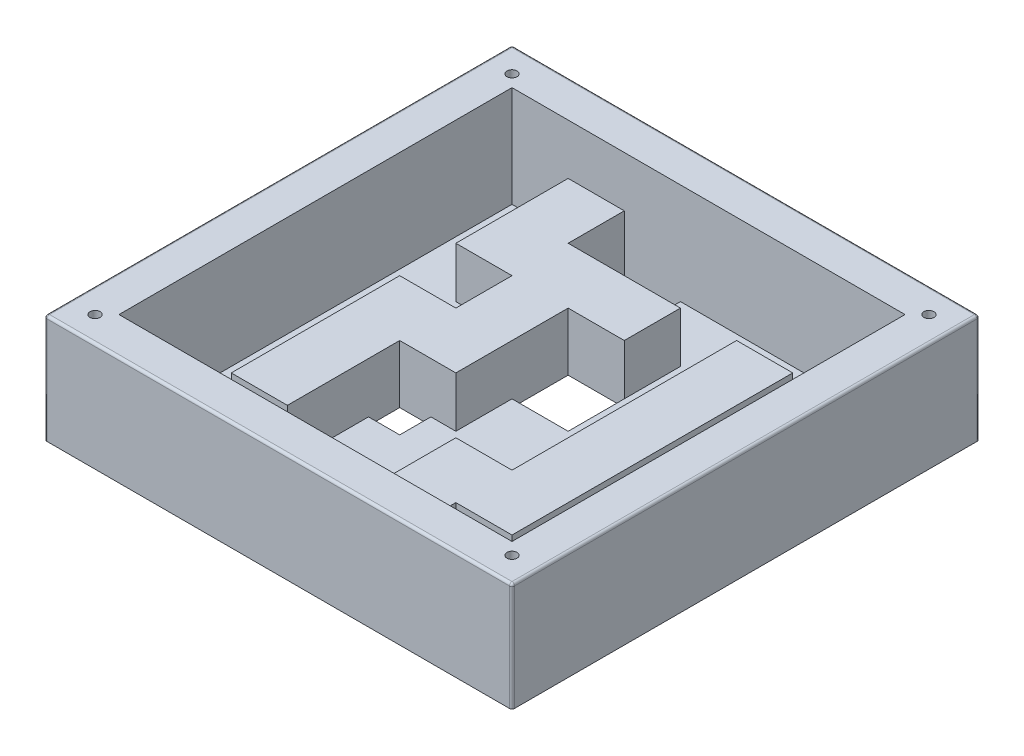
from build123d import *

# Parameters (mm, degrees)
ESQUISSE2_W             = 185
ESQUISSE2_H             = 185
BOSS_EXTRU_1_DEPTH      = 3
ESQUISSE3_W             = 185
ESQUISSE3_H             = 185
ESQUISSE3_W_2           = 155.54
ESQUISSE3_H_2           = 155.54
BOSS_EXTRU_2_DEPTH      = 40
BOSS_EXTRU_3_DEPTH      = 20
ENL_V_MAT_EXTRU_1_REACH = 5
ESQUISSE5_W             = 22.22
ESQUISSE5_H             = 22.22
ESQUISSE5_W_2           = 12.35
ESQUISSE5_H_2           = 12.35
CONG_1_R                = 1
ESQUISSE6_R             = 1
ENL_V_MAT_EXTRU_2_DEPTH = 44
ESQUISSE7_R             = 2
ENL_V_MAT_EXTRU_3_DEPTH = 41


with BuildPart() as part:
    # Esquisse2 → Boss.-Extru.1 (new body)
    with BuildSketch(Plane(origin=(0, 0, 0), x_dir=(1, 0, 0), z_dir=(0, 1, 0))):
        Rectangle(ESQUISSE2_W, ESQUISSE2_H)
    extrude(amount=-BOSS_EXTRU_1_DEPTH)

    # Esquisse3 → Boss.-Extru.2 (add)
    with BuildSketch(Plane(origin=(0, 0, 0), x_dir=(1, 0, 0), z_dir=(0, 1, 0))):
        Rectangle(ESQUISSE3_W, ESQUISSE3_H)
        Rectangle(ESQUISSE3_W_2, ESQUISSE3_H_2, mode=Mode.SUBTRACT)
    extrude(amount=BOSS_EXTRU_2_DEPTH)

    # Esquisse4 → Boss.-Extru.3 (add)
    with BuildSketch(Plane(origin=(0, 0, 0), x_dir=(1, 0, 0), z_dir=(0, 1, 0))):
        Polygon((-55.55, 77.77), (-33.33, 77.77), (-33.33, 55.55), (11.11, 55.55), (11.11, 33.33), (-11.11, 33.33), (-11.11, -11.11), (-33.33, -11.11), (-33.33, -55.55), (-55.55, -55.55), (-55.55, 11.11), (-33.33, 11.11), (-33.33, 33.33), (-55.55, 33.33), align=None)
        Polygon((33.33, 55.55), (55.55, 55.55), (55.55, -55.55), (33.33, -55.55), (33.33, -77.77), (11.11, -77.77), (11.11, -33.33), (33.33, -33.33), align=None)
    extrude(amount=BOSS_EXTRU_3_DEPTH)

    # Esquisse5 → Enlèv. mat.-Extru.1 (cut, up to next)
    with BuildSketch(Plane(origin=(0, 0, 0), x_dir=(1, 0, 0), z_dir=(0, 1, 0)), mode=Mode.PRIVATE) as enl_v_mat_extru_1_sk1:
        with Locations((-22.22, 66.66)):
            Rectangle(ESQUISSE5_W, ESQUISSE5_H)
    enl_v_mat_extru_1_tool1 = extrude(enl_v_mat_extru_1_sk1.sketch, amount=-ENL_V_MAT_EXTRU_1_REACH, mode=Mode.PRIVATE) & part.part
    add(enl_v_mat_extru_1_tool1.solids().sort_by_distance((-22.22, 0, -66.66))[0], mode=Mode.SUBTRACT)
    # Esquisse5 → Enlèv. mat.-Extru.1 (cut, up to next)
    with BuildSketch(Plane(origin=(0, 0, 0), x_dir=(1, 0, 0), z_dir=(0, 1, 0)), mode=Mode.PRIVATE) as enl_v_mat_extru_1_sk2:
        with Locations((0, 22.22)):
            Rectangle(ESQUISSE5_W, ESQUISSE5_H)
    enl_v_mat_extru_1_tool2 = extrude(enl_v_mat_extru_1_sk2.sketch, amount=-ENL_V_MAT_EXTRU_1_REACH, mode=Mode.PRIVATE) & part.part
    add(enl_v_mat_extru_1_tool2.solids().sort_by_distance((0, 0, -22.22))[0], mode=Mode.SUBTRACT)
    # Esquisse5 → Enlèv. mat.-Extru.1 (cut, up to next)
    with BuildSketch(Plane(origin=(0, 0, 0), x_dir=(1, 0, 0), z_dir=(0, 1, 0)), mode=Mode.PRIVATE) as enl_v_mat_extru_1_sk3:
        with Locations((-27.155, -17.285)):
            Rectangle(ESQUISSE5_W_2, ESQUISSE5_H_2)
    enl_v_mat_extru_1_tool3 = extrude(enl_v_mat_extru_1_sk3.sketch, amount=-ENL_V_MAT_EXTRU_1_REACH, mode=Mode.PRIVATE) & part.part
    add(enl_v_mat_extru_1_tool3.solids().sort_by_distance((-27.155, 0, 17.285))[0], mode=Mode.SUBTRACT)
    # Esquisse5 → Enlèv. mat.-Extru.1 (cut, up to next)
    with BuildSketch(Plane(origin=(0, 0, 0), x_dir=(1, 0, 0), z_dir=(0, 1, 0)), mode=Mode.PRIVATE) as enl_v_mat_extru_1_sk4:
        with Locations((-66.66, 22.22)):
            Rectangle(ESQUISSE5_W_2, ESQUISSE5_H_2)
    enl_v_mat_extru_1_tool4 = extrude(enl_v_mat_extru_1_sk4.sketch, amount=-ENL_V_MAT_EXTRU_1_REACH, mode=Mode.PRIVATE) & part.part
    add(enl_v_mat_extru_1_tool4.solids().sort_by_distance((-66.66, 0, -22.22))[0], mode=Mode.SUBTRACT)
    # Esquisse5 → Enlèv. mat.-Extru.1 (cut, up to next)
    with BuildSketch(Plane(origin=(0, 0, 0), x_dir=(1, 0, 0), z_dir=(0, 1, 0)), mode=Mode.PRIVATE) as enl_v_mat_extru_1_sk5:
        with Locations((-66.66, -66.66)):
            Rectangle(ESQUISSE5_W_2, ESQUISSE5_H_2)
    enl_v_mat_extru_1_tool5 = extrude(enl_v_mat_extru_1_sk5.sketch, amount=-ENL_V_MAT_EXTRU_1_REACH, mode=Mode.PRIVATE) & part.part
    add(enl_v_mat_extru_1_tool5.solids().sort_by_distance((-66.66, 0, 66.66))[0], mode=Mode.SUBTRACT)
    # Esquisse5 → Enlèv. mat.-Extru.1 (cut, up to next)
    with BuildSketch(Plane(origin=(0, 0, 0), x_dir=(1, 0, 0), z_dir=(0, 1, 0)), mode=Mode.PRIVATE) as enl_v_mat_extru_1_sk6:
        with Locations((66.66, -66.66)):
            Rectangle(ESQUISSE5_W_2, ESQUISSE5_H_2)
    enl_v_mat_extru_1_tool6 = extrude(enl_v_mat_extru_1_sk6.sketch, amount=-ENL_V_MAT_EXTRU_1_REACH, mode=Mode.PRIVATE) & part.part
    add(enl_v_mat_extru_1_tool6.solids().sort_by_distance((66.66, 0, 66.66))[0], mode=Mode.SUBTRACT)
    # Esquisse5 → Enlèv. mat.-Extru.1 (cut, up to next)
    with BuildSketch(Plane(origin=(0, 0, 0), x_dir=(1, 0, 0), z_dir=(0, 1, 0)), mode=Mode.PRIVATE) as enl_v_mat_extru_1_sk7:
        with Locations((4.935, -49.375)):
            Rectangle(ESQUISSE5_W_2, ESQUISSE5_H_2)
    enl_v_mat_extru_1_tool7 = extrude(enl_v_mat_extru_1_sk7.sketch, amount=-ENL_V_MAT_EXTRU_1_REACH, mode=Mode.PRIVATE) & part.part
    add(enl_v_mat_extru_1_tool7.solids().sort_by_distance((4.935, 0, 49.375))[0], mode=Mode.SUBTRACT)

    # Congé1
    cong_1_edges = [part.edges().sort_by_distance(p)[0] for p in [
        (-92.5, 40, 0),
        (0, 40, 92.5),
        (92.5, 40, 0),
        (0, 40, -92.5),
        (-92.5, 18.5, -92.5),
        (92.5, 18.5, -92.5),
        (92.5, 18.5, 92.5),
        (-92.5, 18.5, 92.5),
    ]]
    fillet(cong_1_edges, radius=CONG_1_R)

    # Esquisse6 → Enlèv. mat.-Extru.2 (cut, through all)
    with BuildSketch(Plane(origin=(0, 40, 0), x_dir=(1, 0, 0), z_dir=(0, 1, 0))):
        with Locations(Location((-82.5, -82.5, 0), (0, 0, 270))):  # turned: the seam where the file's is
            Circle(ESQUISSE6_R)
        with Locations(Location((82.5, -82.5, 0), (0, 0, 270))):  # turned: the seam where the file's is
            Circle(ESQUISSE6_R)
        with Locations(Location((82.5, 82.5, 0), (0, 0, 270))):  # turned: the seam where the file's is
            Circle(ESQUISSE6_R)
        with Locations(Location((-82.5, 82.5, 0), (0, 0, 270))):  # turned: the seam where the file's is
            Circle(ESQUISSE6_R)
    extrude(amount=-ENL_V_MAT_EXTRU_2_DEPTH, mode=Mode.SUBTRACT)

    # Esquisse7 → Enlèv. mat.-Extru.3 (cut)
    with BuildSketch(Plane(origin=(0, 40, 0), x_dir=(1, 0, 0), z_dir=(0, 1, 0))):
        with Locations(Location((-82.5, -82.5, 0), (0, 0, 270))):  # turned: the seam where the file's is
            Circle(ESQUISSE7_R)
        with Locations(Location((-82.5, 82.5, 0), (0, 0, 270))):  # turned: the seam where the file's is
            Circle(ESQUISSE7_R)
        with Locations(Location((82.5, 82.5, 0), (0, 0, 270))):  # turned: the seam where the file's is
            Circle(ESQUISSE7_R)
        with Locations(Location((82.5, -82.5, 0), (0, 0, 270))):  # turned: the seam where the file's is
            Circle(ESQUISSE7_R)
    extrude(amount=-ENL_V_MAT_EXTRU_3_DEPTH, mode=Mode.SUBTRACT)


solid = part.part
